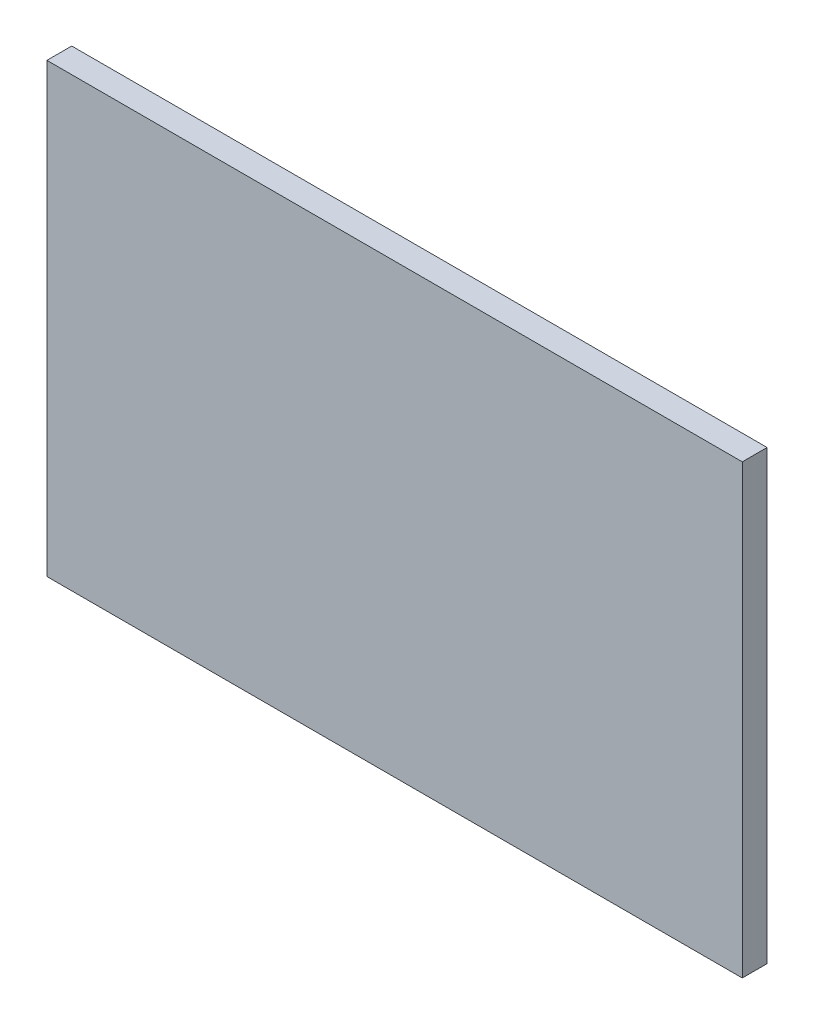
from build123d import *

# Parameters (mm, degrees)
SKETCH1_W           = 88.9
SKETCH1_H           = 57.15
BOSS_EXTRUDE1_DEPTH = 3.175


with BuildPart() as part:
    # Sketch1 → Boss-Extrude1 (new body)
    with BuildSketch(Plane.XY):
        with Locations((44.45, 28.575)):
            Rectangle(SKETCH1_W, SKETCH1_H)
    extrude(amount=BOSS_EXTRUDE1_DEPTH)


solid = part.part
